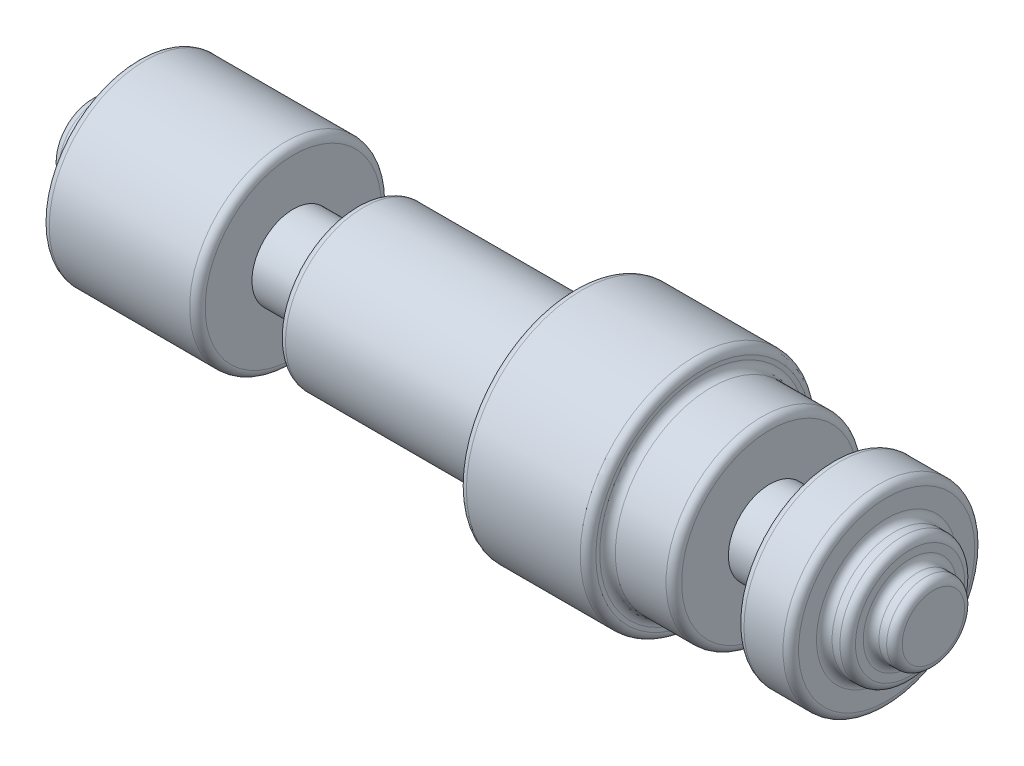
from build123d import *

# Parameters (mm, degrees)
FILLET1_R = 0.254
FILLET2_R = 0.254


with BuildPart() as part:
    # Sketch1 → Revolve1 (revolve)
    with BuildSketch(Plane.XY):
        Polygon((0, 0), (27.4574, 0), (27.4574, 1.27), (26.6954, 1.27), (26.6954, 2.032), (25.9334, 2.032), (25.9334, 3.1242), (24.1554, 3.1242), (24.1554, 1.3462), (22.1234, 1.3462), (22.1234, 3.1242), (19.9644, 3.1242), (19.9644, 3.7592), (15.748, 3.7592), (15.748, 2.54), (8.636, 2.54), (8.636, 1.3462), (6.604, 1.3462), (6.604, 3.1242), (1.524, 3.1242), (1.524, 2.032), (0.762, 2.032), (0.762, 1.27), (0, 1.27), align=None)
    revolve(axis=Axis((0, 0, 0), (-1, 0, 0)))

    # Fillet1
    fillet1_edges = [part.edges().sort_by_distance(p)[0] for p in [
        (1.524, -3.1242, 0),
        (1.524, -2.032, 0),
        (0.762, -2.032, 0),
        (0.762, -1.27, 0),
        (0, -1.27, 0),
    ]]
    fillet(fillet1_edges, radius=FILLET1_R)

    # Fillet2
    fillet2_edges = [part.edges().sort_by_distance(p)[0] for p in [
        (27.4574, -1.27, 0),
        (26.6954, -1.27, 0),
        (26.6954, -2.032, 0),
        (25.9334, -2.032, 0),
        (25.9334, -3.1242, 0),
        (24.1554, -3.1242, 0),
        (22.1234, -3.1242, 0),
        (19.9644, -3.1242, 0),
        (19.9644, -3.7592, 0),
        (15.748, -3.7592, 0),
        (8.636, -2.54, 0),
        (6.604, -3.1242, 0),
    ]]
    fillet(fillet2_edges, radius=FILLET2_R)


solid = part.part
